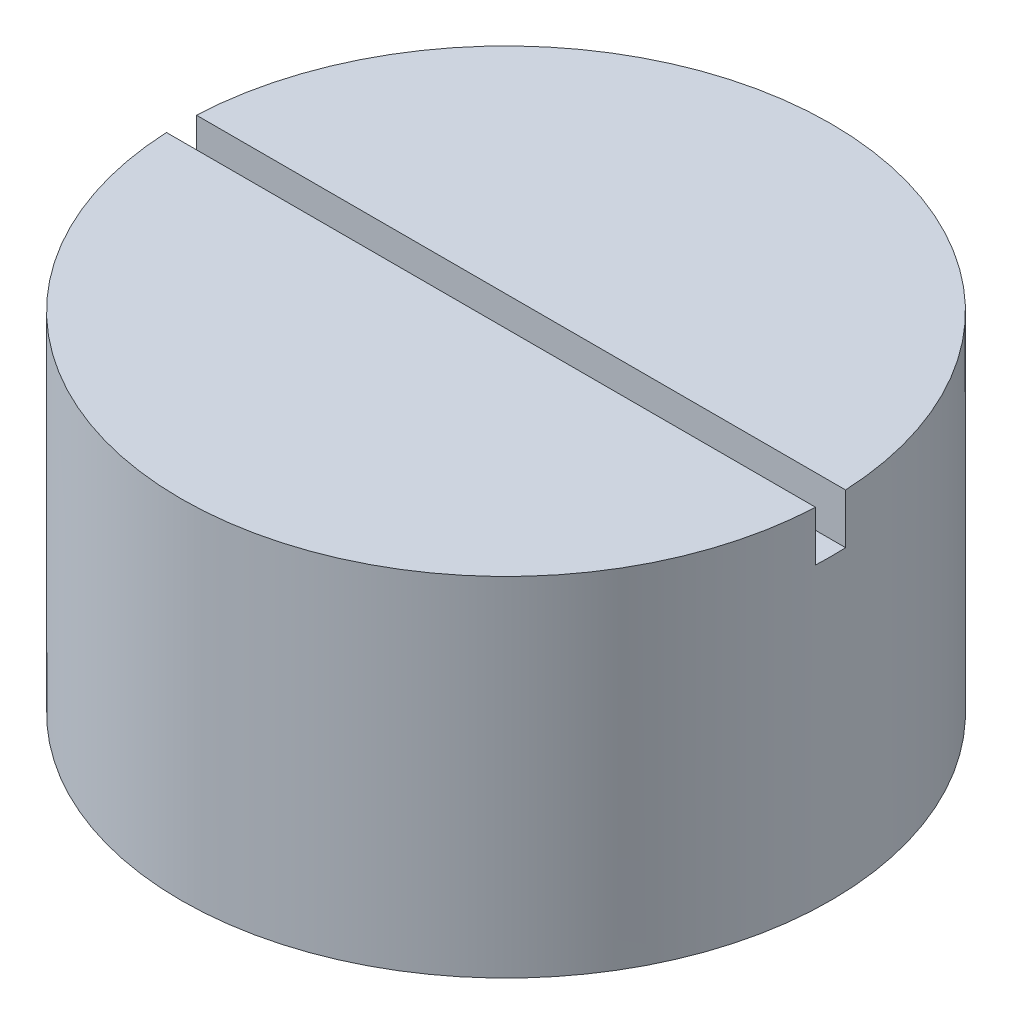
from build123d import *

# Parameters (mm, degrees)
SKETCH1_R           = 32.5
BOSS_EXTRUDE1_DEPTH = 34.793
SKETCH4_W           = 66.380152204
SKETCH4_H           = 3
CUT_EXTRUDE1_DEPTH  = 5
SKETCH5_R           = 8
SKETCH5_R_2         = 6
CUT_EXTRUDE2_DEPTH  = 2


with BuildPart() as part:
    # Sketch1 → Boss-Extrude1 (new body)
    with BuildSketch(Plane(origin=(0, 0, 0), x_dir=(1, 0, 0), z_dir=(0, 1, 0))):
        Circle(SKETCH1_R)
    extrude(amount=BOSS_EXTRUDE1_DEPTH)

    # Sketch4 → Cut-Extrude1 (cut)
    with BuildSketch(Plane(origin=(0, 34.793, 0), x_dir=(1, 0, 0), z_dir=(0, 1, 0))):
        Rectangle(SKETCH4_W, SKETCH4_H)
    extrude(amount=-CUT_EXTRUDE1_DEPTH, mode=Mode.SUBTRACT)

    # Sketch5 → Cut-Extrude2 (cut)
    with BuildSketch(Plane.XZ):
        Circle(SKETCH5_R)
        Circle(SKETCH5_R_2, mode=Mode.SUBTRACT)
    extrude(amount=-CUT_EXTRUDE2_DEPTH, mode=Mode.SUBTRACT)


solid = part.part
